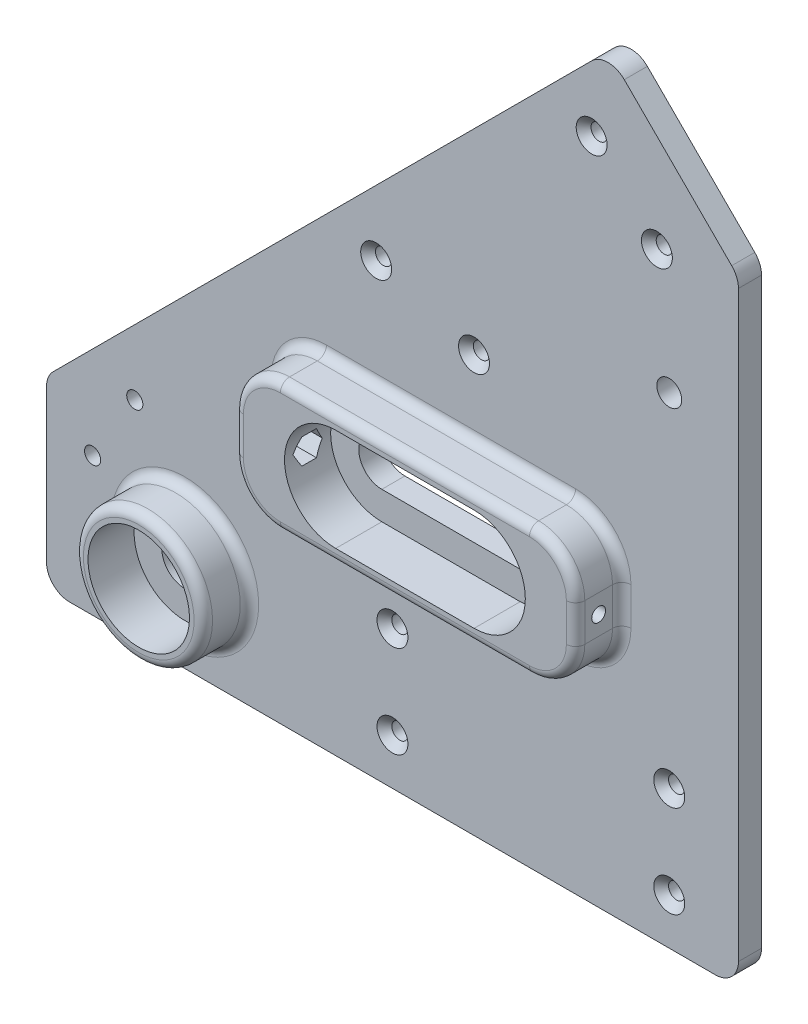
from build123d import *

# Parameters (mm, degrees)
SKETCH1_R               = 5
SKETCH1_R_2             = 1.75
SKETCH1_R_3             = 2.7
BOSS_EXTRUDE1_DEPTH     = 5
SKETCH2_R               = 14
SKETCH2_R_2             = 11
SKETCH2_W               = 74
SKETCH2_H               = 28.2
BOSS_EXTRUDE2_DEPTH     = 10
CHAMFER1_SIZE           = 1.6
FILLET1_R               = 10
SKETCH3_R               = 1.5
CUT_EXTRUDE1_DEPTH      = 100.305288875
CUT_EXTRUDE3_DEPTH      = 57.1
CUT_EXTRUDE3_DEPTH_BACK = 5
FILLET2_R               = 2
FILLET3_R               = 2
FILLET4_R               = 5


with BuildPart() as part:
    # Sketch1 → Boss-Extrude1 (new body)
    with BuildSketch(Plane.XY):
        Polygon((-75, 20), (46.715728753, 141.715728753), (75, 113.431457505), (75, 20), (75, -20), (-75, -20), align=None)
        with Locations((-45, 0)):
            Circle(SKETCH1_R, mode=Mode.SUBTRACT)
        with Locations((-65, -10)):
            Circle(SKETCH1_R_2, mode=Mode.SUBTRACT)
        with Locations((0, 10)):
            Circle(SKETCH1_R_2, mode=Mode.SUBTRACT)
        with Locations((60, -10)):
            Circle(SKETCH1_R_2, mode=Mode.SUBTRACT)
        with Locations((-55.857864376, 25)):
            Circle(SKETCH1_R_2, mode=Mode.SUBTRACT)
        with Locations((43.180194847, 124.038059223)):
            Circle(SKETCH1_R_2, mode=Mode.SUBTRACT)
        with Locations((-27.573593129, 25)):
            Circle(SKETCH1_R_2, mode=Mode.SUBTRACT)
        with Locations((57.32233047, 109.895923599)):
            Circle(SKETCH1_R_2, mode=Mode.SUBTRACT)
        with Locations((-3.535533906, 77.32233047)):
            Circle(SKETCH1_R_2, mode=Mode.SUBTRACT)
        with Locations((17.67766953, 70.251262658)):
            Circle(SKETCH1_R_2, mode=Mode.SUBTRACT)
        with Locations((60, 10)):
            Circle(SKETCH1_R_2, mode=Mode.SUBTRACT)
        with Locations((-65, 10)):
            Circle(SKETCH1_R_2, mode=Mode.SUBTRACT)
        with Locations((0, -10)):
            Circle(SKETCH1_R_2, mode=Mode.SUBTRACT)
        with Locations((60, 84.289321881)):
            Circle(SKETCH1_R_3, mode=Mode.SUBTRACT)
        with BuildLine():
            Line((-2.305288875, 45), (27.694711125, 45))
            ThreePointArc((27.694711125, 45), (32.694711125, 40), (27.694711125, 35))
            Line((27.694711125, 35), (-2.305288875, 35))
            ThreePointArc((-2.305288875, 35), (-7.305288875, 40), (-2.305288875, 45))
        make_face(mode=Mode.SUBTRACT)
    extrude(amount=BOSS_EXTRUDE1_DEPTH)

    # Sketch2 → Boss-Extrude2 (add)
    with BuildSketch(Plane.XY.offset(5)):
        with Locations((-45, 0)):
            Circle(SKETCH2_R)
        with Locations((-45, 0)):
            Circle(SKETCH2_R_2, mode=Mode.SUBTRACT)
        with Locations((12.694711125, 40)):
            Rectangle(SKETCH2_W, SKETCH2_H)
        with BuildLine():
            Line((-2.305288875, 51.1), (27.694711125, 51.1))
            ThreePointArc((27.694711125, 51.1), (38.794711125, 40), (27.694711125, 28.9))
            Line((27.694711125, 28.9), (-2.305288875, 28.9))
            ThreePointArc((-2.305288875, 28.9), (-13.405288875, 40), (-2.305288875, 51.1))
        make_face(mode=Mode.SUBTRACT)
    extrude(amount=BOSS_EXTRUDE2_DEPTH)

    # Chamfer1
    chamfer1_edges = [part.edges().sort_by_distance(p)[0] for p in [
        (-1.75, -10, 5),
        (58.25, 10, 5),
        (15.92766953, 70.251262658, 5),
        (-5.285533906, 77.32233047, 5),
        (55.57233047, 109.895923599, 5),
        (-29.323593129, 25, 5),
        (41.430194847, 124.038059223, 5),
        (58.25, -10, 5),
        (-1.75, 10, 5),
    ]]
    chamfer(chamfer1_edges, length=CHAMFER1_SIZE)

    # Fillet1
    fillet1_edges = [part.edges().sort_by_distance(p)[0] for p in [
        (49.694711125, 25.9, 10),
        (49.694711125, 54.1, 10),
        (-24.305288875, 54.1, 10),
        (-24.305288875, 25.9, 10),
    ]]
    fillet(fillet1_edges, radius=FILLET1_R)

    # Sketch3 → Cut-Extrude1 (cut, through all)
    with BuildSketch(Plane.ZY.offset(24.305288875)):
        with Locations((10, 40)):
            Circle(SKETCH3_R)
    extrude(amount=-CUT_EXTRUDE1_DEPTH, mode=Mode.SUBTRACT)

    # Sketch4 → Cut-Extrude3 (cut, two sides)
    with BuildSketch(Plane(origin=(-13.405288875, 0, 0), x_dir=(0, 0, -1), z_dir=(1, 0, 0))) as cut_extrude3_sk:
        Polygon((-6.824573519, 40), (-8.41228676, 42.75), (-11.58771324, 42.75), (-13.175426481, 40), (-11.58771324, 37.25), (-8.41228676, 37.25), align=None)
    extrude(amount=CUT_EXTRUDE3_DEPTH, mode=Mode.SUBTRACT)
    extrude(cut_extrude3_sk.sketch, amount=-CUT_EXTRUDE3_DEPTH_BACK, mode=Mode.SUBTRACT)

    # Fillet2
    fillet2_edges = [part.edges().sort_by_distance(p)[0] for p in [
        (49.694711125, 40, 5),
        (12.694711125, 25.9, 5),
        (12.694711125, 54.1, 5),
        (-24.305288875, 40, 5),
        (46.765778937, 28.828932188, 5),
        (46.765778937, 51.171067812, 5),
        (-21.376356686, 28.828932188, 5),
        (-21.376356686, 51.171067812, 5),
        (-59, 0, 5),
    ]]
    fillet(fillet2_edges, radius=FILLET2_R)

    # Fillet3
    fillet3_edges = [part.edges().sort_by_distance(p)[0] for p in [
        (49.694711125, 40, 15),
        (12.694711125, 25.9, 15),
        (12.694711125, 54.1, 15),
        (-24.305288875, 40, 15),
        (-21.376356686, 51.171067812, 15),
        (-21.376356686, 28.828932188, 15),
        (46.765778937, 51.171067812, 15),
        (46.765778937, 28.828932188, 15),
        (-59, 0, 15),
    ]]
    fillet(fillet3_edges, radius=FILLET3_R)

    # Fillet4
    fillet4_edges = [part.edges().sort_by_distance(p)[0] for p in [
        (75, -20, 2.5),
        (-75, -20, 2.5),
        (-75, 20, 2.5),
        (46.715728753, 141.715728753, 2.5),
        (75, 113.431457505, 2.5),
    ]]
    fillet(fillet4_edges, radius=FILLET4_R)


solid = part.part
